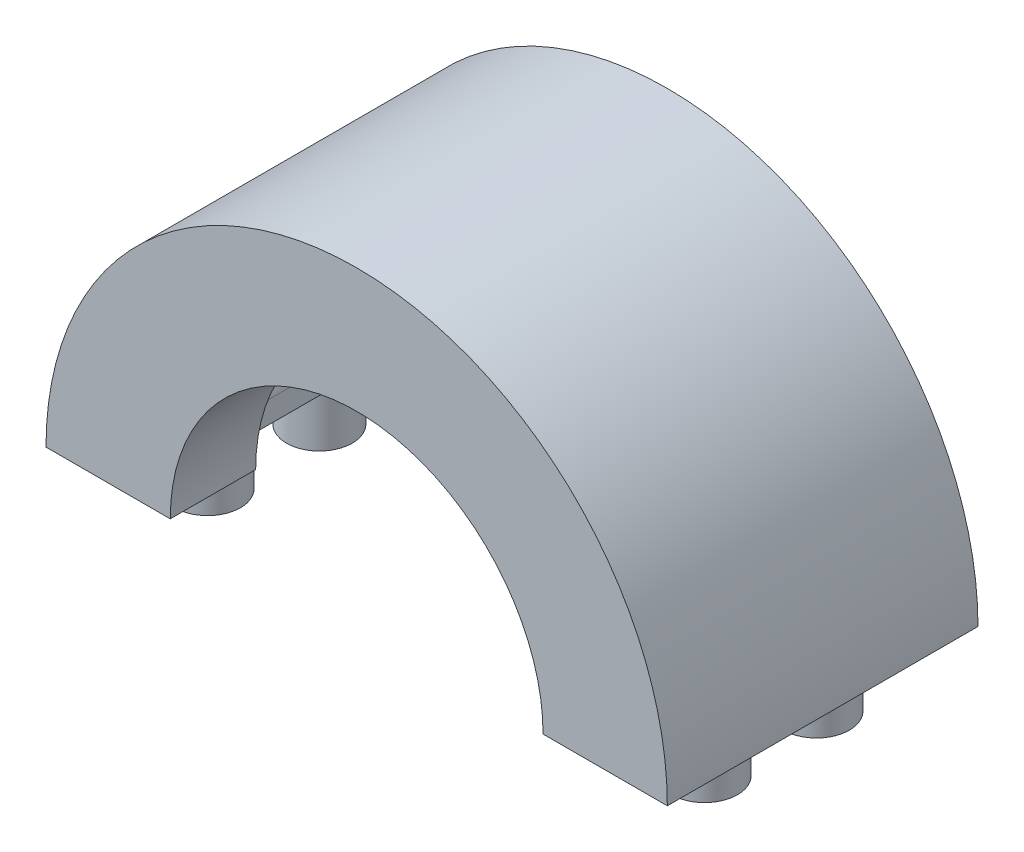
from build123d import *

# Parameters (mm, degrees)
BOSS_EXTRUDE1_DEPTH = 12.5
CUT_EXTRUDE1_DEPTH  = 5.628
FILLET5_R           = 2
CHAMFER9_SIZE       = 2
SKETCH4_R           = 2.64775
BOSS_EXTRUDE2_DEPTH = 4.4055


with BuildPart() as part:
    # Sketch1 → Boss-Extrude1 (new body, symmetric)
    with BuildSketch(Plane.XY):
        with BuildLine():
            Line((-25, 0), (-15, 0))
            ThreePointArc((-15, 0), (0, 15), (15, 0))
            Line((15, 0), (25, 0))
            ThreePointArc((25, 0), (0, 25), (-25, 0))
        make_face()
    extrude(amount=BOSS_EXTRUDE1_DEPTH, both=True)

    # Sketch3 → Cut-Extrude1 (cut, symmetric)
    with BuildSketch(Plane(origin=(0, 0, 0), x_dir=(-1, 0, 0), z_dir=(0, 0, -1))):
        with BuildLine():
            Line((15, 0), (15.5936, 0))
            Line((15.5936, 0), (15.5936, 4.536))
            Line((15.5936, 4.536), (16.6576, 5.712))
            Line((16.6576, 5.712), (16.6576, 8.008))
            Line((16.6576, 8.008), (12.683530108, 8.008))
            ThreePointArc((12.683530108, 8.008), (14.409249662, 4.16815597), (15, 0))
        make_face()
    cut_extrude1 = extrude(amount=CUT_EXTRUDE1_DEPTH, both=True, mode=Mode.SUBTRACT)

    # Mirror3: Cut-Extrude1 across plane
    add(cut_extrude1.mirror(Plane(origin=(0, 0, 0), x_dir=(0, 0, 1), z_dir=(1, 0, 0))), mode=Mode.SUBTRACT)

    # Fillet5
    fillet5_edges = [part.edges().sort_by_distance(p)[0] for p in [
        (-15.5936, 4.536, 0),
        (15.5936, 4.536, 0),
    ]]
    fillet(fillet5_edges, radius=FILLET5_R)

    # Chamfer9
    chamfer9_edges = [part.edges().sort_by_distance(p)[0] for p in [
        (-15.5936, 0, 0),
        (15.5936, 0, 0),
    ]]
    chamfer(chamfer9_edges, length=CHAMFER9_SIZE)

    # Sketch4 → Boss-Extrude2 (add)
    with BuildSketch(Plane.XZ):
        with Locations((-20, 4.5)):
            Circle(SKETCH4_R)
        with Locations((-20, -4.5)):
            Circle(SKETCH4_R)
    boss_extrude2 = extrude(amount=BOSS_EXTRUDE2_DEPTH)

    # Mirror4: Boss-Extrude2 across plane
    add(boss_extrude2.mirror(Plane(origin=(0, 0, 0), x_dir=(0, 0, 1), z_dir=(1, 0, 0))))


solid = part.part
